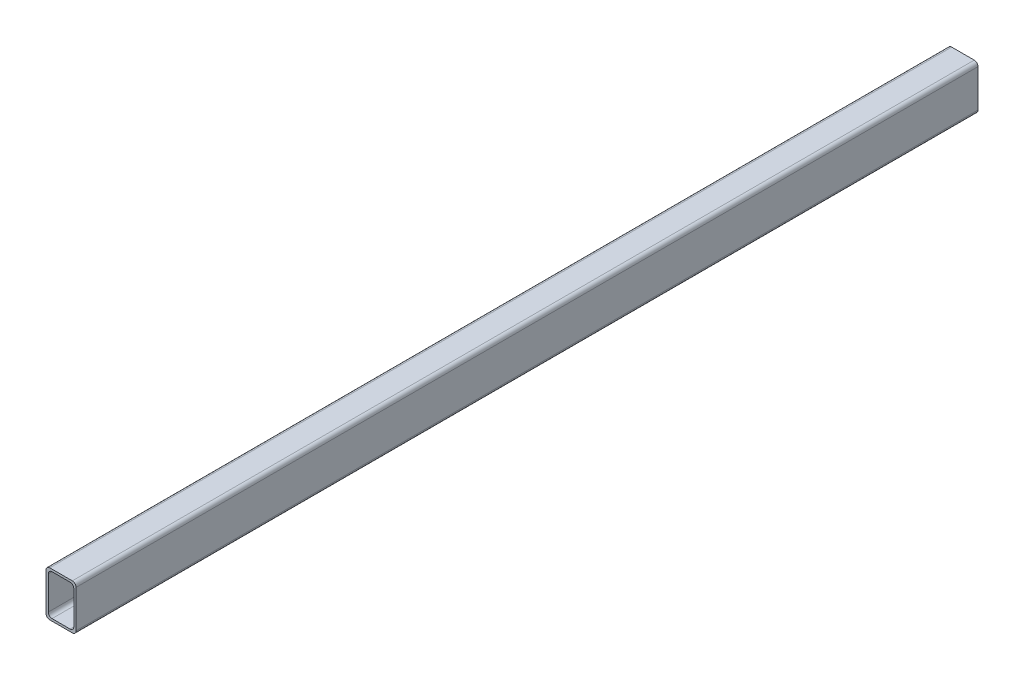
from build123d import *

# Parameters (mm, degrees)
SALIENTE_EXTRUIR1_DEPTH = 1200


with BuildPart() as part:
    # Croquis1 → Saliente-Extruir1 (new body)
    with BuildSketch(Plane.XY):
        with BuildLine():
            Line((-15, -30), (15, -30))
            ThreePointArc((15, -30), (18.535533906, -28.535533906), (20, -25))
            Line((20, -25), (20, 25))
            ThreePointArc((20, 25), (18.535533906, 28.535533906), (15, 30))
            Line((15, 30), (-15, 30))
            ThreePointArc((-15, 30), (-18.535533906, 28.535533906), (-20, 25))
            Line((-20, 25), (-20, -25))
            ThreePointArc((-20, -25), (-18.535533906, -28.535533906), (-15, -30))
        make_face()
        with BuildLine():
            Line((-12, -27), (12, -27))
            ThreePointArc((12, -27), (15.535533906, -25.535533906), (17, -22))
            Line((17, -22), (17, 22))
            ThreePointArc((17, 22), (15.535533906, 25.535533906), (12, 27))
            Line((12, 27), (-12, 27))
            ThreePointArc((-12, 27), (-15.535533906, 25.535533906), (-17, 22))
            Line((-17, 22), (-17, -22))
            ThreePointArc((-17, -22), (-15.535533906, -25.535533906), (-12, -27))
        make_face(mode=Mode.SUBTRACT)
    extrude(amount=SALIENTE_EXTRUIR1_DEPTH)


solid = part.part
